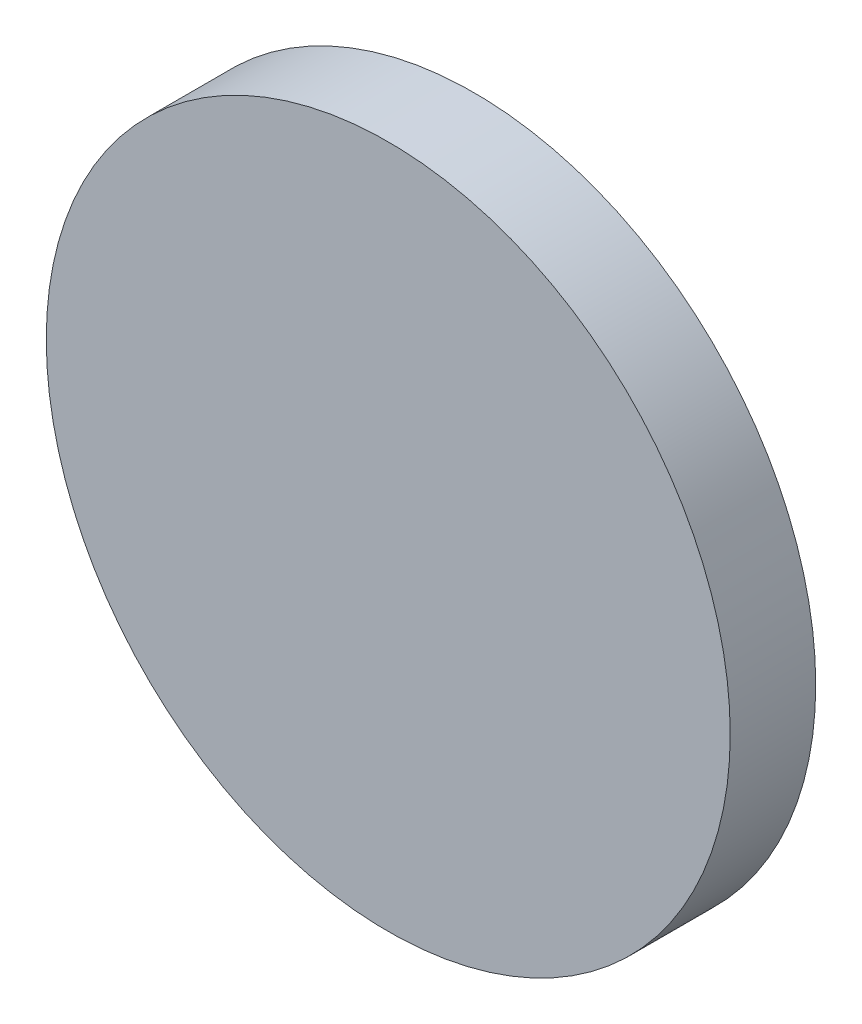
from build123d import *

# Parameters (mm, degrees)
SKETCH1_R           = 3.175
BOSS_EXTRUDE1_DEPTH = 0.79375


with BuildPart() as part:
    # Sketch1 → Boss-Extrude1 (new body)
    with BuildSketch(Plane.XY):
        Circle(SKETCH1_R)
    extrude(amount=BOSS_EXTRUDE1_DEPTH)


solid = part.part
